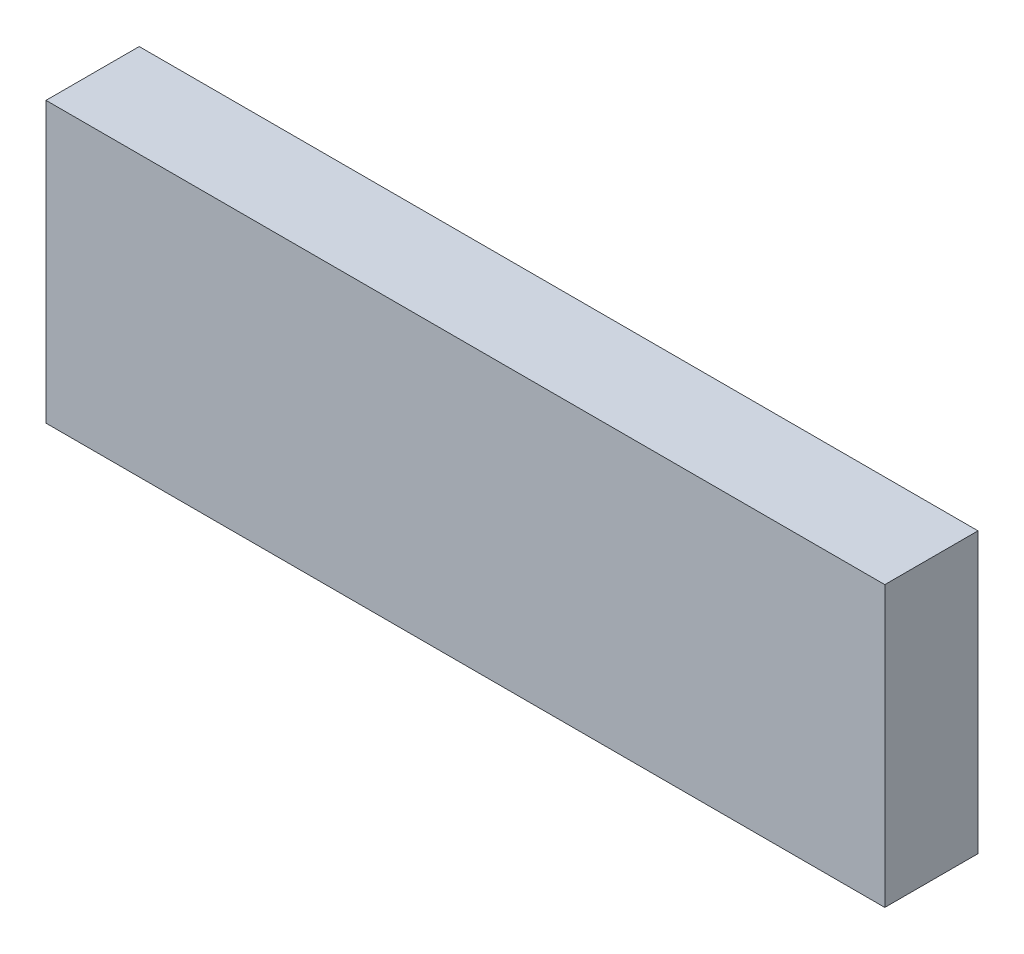
from build123d import *

# Parameters (mm, degrees)
SKETCH1_W           = 180
SKETCH1_H           = 60
BOSS_EXTRUDE1_DEPTH = 20


with BuildPart() as part:
    # Sketch1 → Boss-Extrude1 (new body)
    with BuildSketch(Plane.XY):
        Rectangle(SKETCH1_W, SKETCH1_H)
    extrude(amount=BOSS_EXTRUDE1_DEPTH)


solid = part.part
